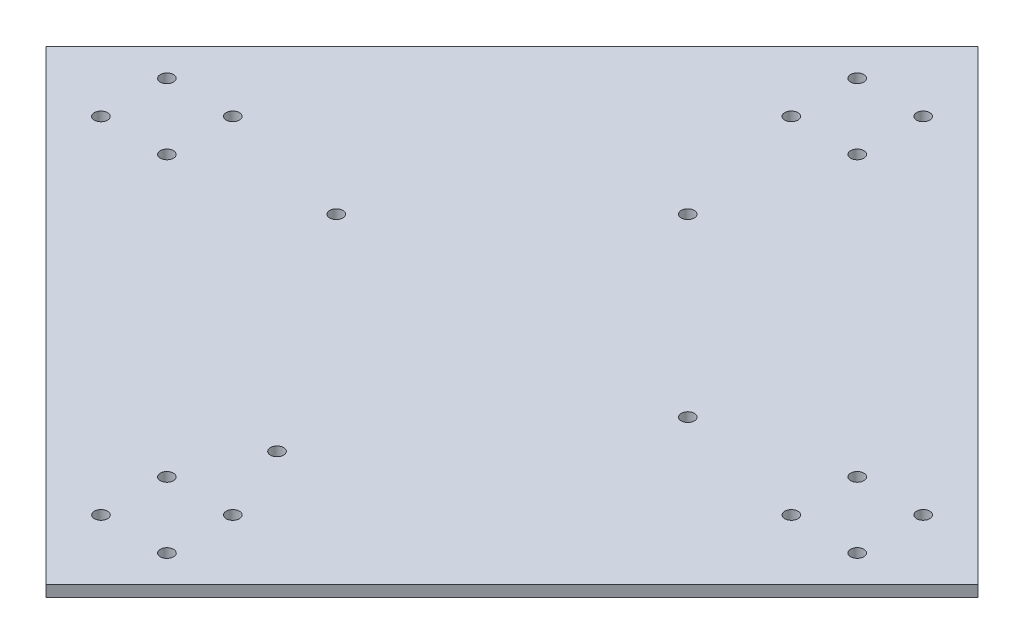
from build123d import *

# Parameters (mm, degrees)
SKETCH3_R           = 1500
BOSS_EXTRUDE2_DEPTH = 2500
SKETCH4_R           = 1500
CUT_EXTRUDE4_DEPTH  = 5000
SCALE1_SCALE        = 0.001


with BuildPart() as part:
    # Sketch3 → Boss-Extrude2 (new body)
    with BuildSketch(Plane(origin=(0, 0, 0), x_dir=(1, 0, 0), z_dir=(0, 1, 0))):
        Polygon((94457.392609736, 188109.713508362), (200523.409787719, 82043.696330379), (94472.169284797, -24037.095464325), (-11608.622509908, 82043.696330379), align=None)
        with Locations((23406.152106819, 74543.696330375)):
            Circle(SKETCH3_R, mode=Mode.SUBTRACT)
        with Locations((8406.152106819, 89543.696330375)):
            Circle(SKETCH3_R, mode=Mode.SUBTRACT)
        with Locations((8406.152106819, 74528.921713652)):
            Circle(SKETCH3_R, mode=Mode.SUBTRACT)
        with Locations((101972.169284806, 10977.679152396)):
            Circle(SKETCH3_R, mode=Mode.SUBTRACT)
        with Locations((86972.169284806, -4022.320847604)):
            Circle(SKETCH3_R, mode=Mode.SUBTRACT)
        with Locations((101986.943901529, -4022.320847604)):
            Circle(SKETCH3_R, mode=Mode.SUBTRACT)
        with Locations((165538.186462784, 89543.696330384)):
            Circle(SKETCH3_R, mode=Mode.SUBTRACT)
        with Locations((180538.186462784, 74543.696330384)):
            Circle(SKETCH3_R, mode=Mode.SUBTRACT)
        with Locations((180538.186462784, 89558.470947106)):
            Circle(SKETCH3_R, mode=Mode.SUBTRACT)
        with Locations((23406.152106818, 89543.696330376)):
            Circle(SKETCH3_R, mode=Mode.SUBTRACT)
        with Locations((86972.169284804, 10977.679152397)):
            Circle(SKETCH3_R, mode=Mode.SUBTRACT)
        with Locations((165538.186462783, 74543.696330383)):
            Circle(SKETCH3_R, mode=Mode.SUBTRACT)
        with Locations((86972.169284797, 153109.713508362)):
            Circle(SKETCH3_R, mode=Mode.SUBTRACT)
        with Locations((101972.169284797, 153109.713508362)):
            Circle(SKETCH3_R, mode=Mode.SUBTRACT)
        with Locations((101972.169284797, 168109.713508362)):
            Circle(SKETCH3_R, mode=Mode.SUBTRACT)
        with Locations((86957.394668074, 168109.713508362)):
            Circle(SKETCH3_R, mode=Mode.SUBTRACT)
    extrude(amount=BOSS_EXTRUDE2_DEPTH)

    # Sketch4 → Cut-Extrude4 (cut)
    with BuildSketch(Plane(origin=(0, 2500, 0), x_dir=(1, 0, 0), z_dir=(0, 1, 0))):
        with Locations((94468.506668684, 28546.60944503)):
            Circle(SKETCH4_R)
        with Locations((54464.69695623, 82043.696330379)):
            Circle(SKETCH4_R)
        with Locations((94461.994310196, 122043.696330379)):
            Circle(SKETCH4_R)
        with Locations((134464.69695623, 82043.696330379)):
            Circle(SKETCH4_R)
    extrude(amount=-CUT_EXTRUDE4_DEPTH, mode=Mode.SUBTRACT)


with BuildPart() as part_1:
    # Scale1: scaled about (94459.787496469, 1250, -82043.00706731)
    add(part.part.scale(SCALE1_SCALE).moved(Location((94365.327708973, 1248.75, -81960.964060243))))


solid = part_1.part
